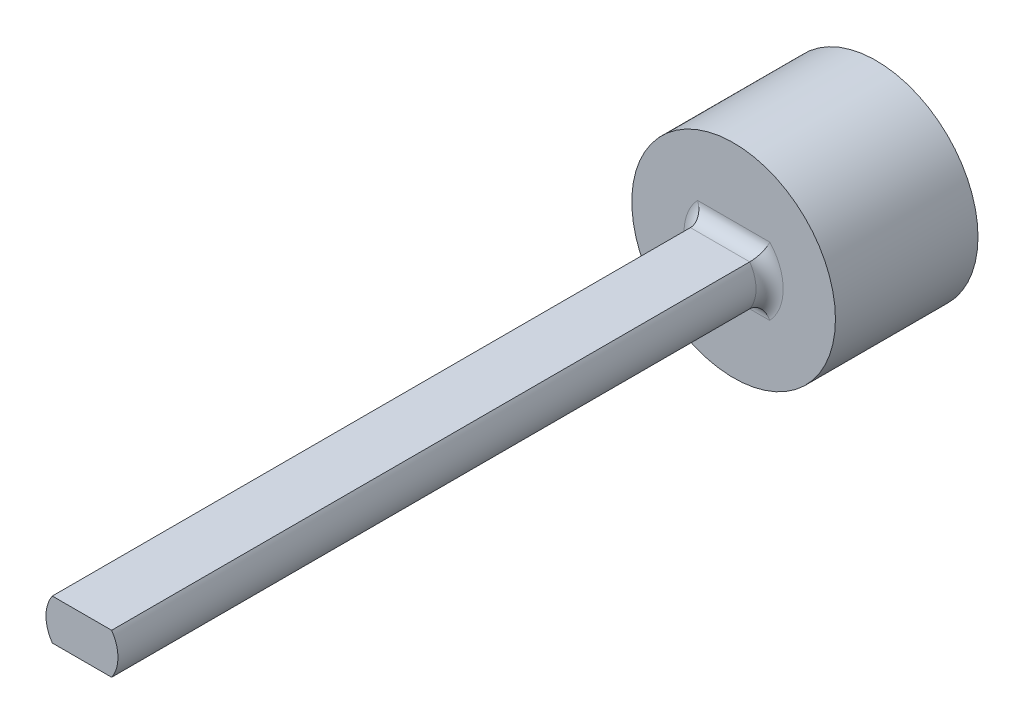
from build123d import *

# Parameters (mm, degrees)
SKETCH2_R                = 7.5
BOSS_EXTRUDE1_DEPTH      = 4
BOSS_EXTRUDE1_DEPTH_BACK = 5.5
SKETCH4_R                = 7.5
BOSS_EXTRUDE2_DEPTH      = 1
BOSS_EXTRUDE3_DEPTH      = 48
FILLET1_R                = 1


with BuildPart() as part:
    # Sketch2 → Boss-Extrude1 (new body, two sides)
    with BuildSketch(Plane.XY) as boss_extrude1_sk:
        with Locations((-178.577921964, 19.246491703)):
            Circle(SKETCH2_R)
        with BuildLine():
            ThreePointArc((-180.964561166, 16.918133172), (-181.154624072, 16.787356328), (-181.28128896, 16.594528692))
            ThreePointArc((-181.28128896, 16.594528692), (-181.41997807, 16.120570829), (-181.458725437, 15.628260596))
            ThreePointArc((-181.458725437, 15.628260596), (-181.203949235, 15.439313513), (-180.936821377, 15.26827369))
            ThreePointArc((-180.936821377, 15.26827369), (-180.490384316, 15.479377161), (-180.096604948, 15.777384768))
            ThreePointArc((-180.096604948, 15.777384768), (-179.961348857, 15.964286563), (-179.906617406, 16.188409207))
            ThreePointArc((-179.906617406, 16.188409207), (-179.860820758, 16.267909453), (-179.769487026, 16.276614146))
            ThreePointArc((-179.769487026, 16.276614146), (-179.651168987, 16.231837357), (-179.531173567, 16.191772177))
            ThreePointArc((-179.531173567, 16.191772177), (-179.465888148, 16.127309504), (-179.480632878, 16.036754465))
            ThreePointArc((-179.480632878, 16.036754465), (-179.57984376, 15.828466942), (-179.593124953, 15.598140867))
            ThreePointArc((-179.593124953, 15.598140867), (-179.476254314, 15.118336763), (-179.263655401, 14.67260991))
            ThreePointArc((-179.263655401, 14.67260991), (-178.948539196, 14.636365038), (-178.631679774, 14.621804135))
            ThreePointArc((-178.631679774, 14.621804135), (-178.350605674, 15.027843634), (-178.158586541, 15.482815477))
            ThreePointArc((-178.158586541, 15.482815477), (-178.134902228, 15.712305225), (-178.199564723, 15.933766853))
            ThreePointArc((-178.199564723, 15.933766853), (-178.199653785, 16.02551441), (-178.1249088, 16.078719761))
            ThreePointArc((-178.1249088, 16.078719761), (-178.000053977, 16.099100944), (-177.876102305, 16.124401191))
            ThreePointArc((-177.876102305, 16.124401191), (-177.787332137, 16.101217588), (-177.754823928, 16.015422258))
            ThreePointArc((-177.754823928, 16.015422258), (-177.736599312, 15.785434531), (-177.632938125, 15.579325702))
            ThreePointArc((-177.632938125, 15.579325702), (-177.29182313, 15.222238479), (-176.884843645, 14.942527158))
            ThreePointArc((-176.884843645, 14.942527158), (-176.59382257, 15.06869628), (-176.312133809, 15.21451588))
            ThreePointArc((-176.312133809, 15.21451588), (-176.271736248, 15.706693451), (-176.332928722, 16.196720191))
            ThreePointArc((-176.332928722, 16.196720191), (-176.427162379, 16.407306299), (-176.593892556, 16.566766447))
            ThreePointArc((-176.593892556, 16.566766447), (-176.639843465, 16.646177632), (-176.601715085, 16.72962731))
            ThreePointArc((-176.601715085, 16.72962731), (-176.503778228, 16.809705343), (-176.409083055, 16.893591835))
            ThreePointArc((-176.409083055, 16.893591835), (-176.320614032, 16.917899331), (-176.249563433, 16.8598525))
            ThreePointArc((-176.249563433, 16.8598525), (-176.118786588, 16.669789594), (-175.925958953, 16.543124706))
            ThreePointArc((-175.925958953, 16.543124706), (-175.45200109, 16.404435596), (-174.959690856, 16.365688229))
            ThreePointArc((-174.959690856, 16.365688229), (-174.770743774, 16.620464432), (-174.599703951, 16.88759229))
            ThreePointArc((-174.599703951, 16.88759229), (-174.810807422, 17.33402935), (-175.108815029, 17.727808718))
            ThreePointArc((-175.108815029, 17.727808718), (-175.295716824, 17.86306481), (-175.519839467, 17.91779626))
            ThreePointArc((-175.519839467, 17.91779626), (-175.599339714, 17.963592909), (-175.608044407, 18.05492664))
            ThreePointArc((-175.608044407, 18.05492664), (-175.563267617, 18.17324468), (-175.523202438, 18.2932401))
            ThreePointArc((-175.523202438, 18.2932401), (-175.458739765, 18.358525519), (-175.368184725, 18.343780789))
            ThreePointArc((-175.368184725, 18.343780789), (-175.159897203, 18.244569907), (-174.929571128, 18.231288713))
            ThreePointArc((-174.929571128, 18.231288713), (-174.449767024, 18.348159352), (-174.004040171, 18.560758265))
            ThreePointArc((-174.004040171, 18.560758265), (-173.967795299, 18.87587447), (-173.953234396, 19.192733892))
            ThreePointArc((-173.953234396, 19.192733892), (-174.359273895, 19.473807993), (-174.814245738, 19.665827125))
            ThreePointArc((-174.814245738, 19.665827125), (-175.043735485, 19.689511439), (-175.265197114, 19.624848944))
            ThreePointArc((-175.265197114, 19.624848944), (-175.356944671, 19.624759881), (-175.410150022, 19.699504867))
            ThreePointArc((-175.410150022, 19.699504867), (-175.430531205, 19.824359689), (-175.455831451, 19.948311361))
            ThreePointArc((-175.455831451, 19.948311361), (-175.432647848, 20.037081529), (-175.346852519, 20.069589738))
            ThreePointArc((-175.346852519, 20.069589738), (-175.116864792, 20.087814355), (-174.910755963, 20.191475542))
            ThreePointArc((-174.910755963, 20.191475542), (-174.553668739, 20.532590536), (-174.273957418, 20.939570022))
            ThreePointArc((-174.273957418, 20.939570022), (-174.400126541, 21.230591097), (-174.54594614, 21.512279857))
            ThreePointArc((-174.54594614, 21.512279857), (-175.038123712, 21.552677419), (-175.528150452, 21.491484944))
            ThreePointArc((-175.528150452, 21.491484944), (-175.73873656, 21.397251288), (-175.898196708, 21.23052111))
            ThreePointArc((-175.898196708, 21.23052111), (-175.977607892, 21.184570201), (-176.061057571, 21.222698582))
            ThreePointArc((-176.061057571, 21.222698582), (-176.141135604, 21.320635439), (-176.225022096, 21.415330612))
            ThreePointArc((-176.225022096, 21.415330612), (-176.249329591, 21.503799634), (-176.191282761, 21.574850234))
            ThreePointArc((-176.191282761, 21.574850234), (-176.001219855, 21.705627078), (-175.874554967, 21.898454714))
            ThreePointArc((-175.874554967, 21.898454714), (-175.735865857, 22.372412576), (-175.69711849, 22.86472281))
            ThreePointArc((-175.69711849, 22.86472281), (-175.951894692, 23.053669893), (-176.21902255, 23.224709716))
            ThreePointArc((-176.21902255, 23.224709716), (-176.665459611, 23.013606245), (-177.059238979, 22.715598637))
            ThreePointArc((-177.059238979, 22.715598637), (-177.19449507, 22.528696843), (-177.249226521, 22.304574199))
            ThreePointArc((-177.249226521, 22.304574199), (-177.295023169, 22.225073952), (-177.386356901, 22.21636926))
            ThreePointArc((-177.386356901, 22.21636926), (-177.50467494, 22.261146049), (-177.62467036, 22.301211229))
            ThreePointArc((-177.62467036, 22.301211229), (-177.68995578, 22.365673902), (-177.67521105, 22.456228941))
            ThreePointArc((-177.67521105, 22.456228941), (-177.576000167, 22.664516463), (-177.562718974, 22.894842539))
            ThreePointArc((-177.562718974, 22.894842539), (-177.679589613, 23.374646643), (-177.892188526, 23.820373495))
            ThreePointArc((-177.892188526, 23.820373495), (-178.207304731, 23.856618368), (-178.524164153, 23.871179271))
            ThreePointArc((-178.524164153, 23.871179271), (-178.805238253, 23.465139771), (-178.997257386, 23.010167929))
            ThreePointArc((-178.997257386, 23.010167929), (-179.0209417, 22.780678181), (-178.956279204, 22.559216553))
            ThreePointArc((-178.956279204, 22.559216553), (-178.956190142, 22.467468995), (-179.030935127, 22.414263644))
            ThreePointArc((-179.030935127, 22.414263644), (-179.15578995, 22.393882462), (-179.279741622, 22.368582215))
            ThreePointArc((-179.279741622, 22.368582215), (-179.36851179, 22.391765818), (-179.401019999, 22.477561148))
            ThreePointArc((-179.401019999, 22.477561148), (-179.419244616, 22.707548874), (-179.522905803, 22.913657703))
            ThreePointArc((-179.522905803, 22.913657703), (-179.864020797, 23.270744927), (-180.271000283, 23.550456248))
            ThreePointArc((-180.271000283, 23.550456248), (-180.562021357, 23.424287126), (-180.843710118, 23.278467526))
            ThreePointArc((-180.843710118, 23.278467526), (-180.88410768, 22.786289955), (-180.822915205, 22.296263215))
            ThreePointArc((-180.822915205, 22.296263215), (-180.728681548, 22.085677107), (-180.561951371, 21.926216958))
            ThreePointArc((-180.561951371, 21.926216958), (-180.516000462, 21.846805774), (-180.554128842, 21.763356096))
            ThreePointArc((-180.554128842, 21.763356096), (-180.6520657, 21.683278063), (-180.746760873, 21.59939157))
            ThreePointArc((-180.746760873, 21.59939157), (-180.835229895, 21.575084075), (-180.906280494, 21.633130906))
            ThreePointArc((-180.906280494, 21.633130906), (-181.037057339, 21.823193811), (-181.229884975, 21.9498587))
            ThreePointArc((-181.229884975, 21.9498587), (-181.703842837, 22.08854781), (-182.196153071, 22.127295177))
            ThreePointArc((-182.196153071, 22.127295177), (-182.385100154, 21.872518974), (-182.556139976, 21.605391116))
            ThreePointArc((-182.556139976, 21.605391116), (-182.345036505, 21.158954055), (-182.047028898, 20.765174687))
            ThreePointArc((-182.047028898, 20.765174687), (-181.860127103, 20.629918596), (-181.63600446, 20.575187146))
            ThreePointArc((-181.63600446, 20.575187146), (-181.556504213, 20.529390497), (-181.54779952, 20.438056766))
            ThreePointArc((-181.54779952, 20.438056766), (-181.59257631, 20.319738726), (-181.632641489, 20.199743306))
            ThreePointArc((-181.632641489, 20.199743306), (-181.697104162, 20.134457887), (-181.787659202, 20.149202617))
            ThreePointArc((-181.787659202, 20.149202617), (-181.995946724, 20.248413499), (-182.226272799, 20.261694692))
            ThreePointArc((-182.226272799, 20.261694692), (-182.706076904, 20.144824054), (-183.151803756, 19.932225141))
            ThreePointArc((-183.151803756, 19.932225141), (-183.188048629, 19.617108936), (-183.202609531, 19.300249514))
            ThreePointArc((-183.202609531, 19.300249514), (-182.796570032, 19.019175413), (-182.34159819, 18.82715628))
            ThreePointArc((-182.34159819, 18.82715628), (-182.112108442, 18.803471967), (-181.890646814, 18.868134462))
            ThreePointArc((-181.890646814, 18.868134462), (-181.798899256, 18.868223525), (-181.745693905, 18.793478539))
            ThreePointArc((-181.745693905, 18.793478539), (-181.725312723, 18.668623716), (-181.700012476, 18.544672045))
            ThreePointArc((-181.700012476, 18.544672045), (-181.723196079, 18.455901876), (-181.808991408, 18.423393667))
            ThreePointArc((-181.808991408, 18.423393667), (-182.038979135, 18.405169051), (-182.245087964, 18.301507864))
            ThreePointArc((-182.245087964, 18.301507864), (-182.602175188, 17.96039287), (-182.881886509, 17.553413384))
            ThreePointArc((-182.881886509, 17.553413384), (-182.755717387, 17.262392309), (-182.609897787, 16.980703549))
            ThreePointArc((-182.609897787, 16.980703549), (-182.117720216, 16.940305987), (-181.627693476, 17.001498461))
            ThreePointArc((-181.627693476, 17.001498461), (-181.417107367, 17.095732118), (-181.257647219, 17.262462296))
            ThreePointArc((-181.257647219, 17.262462296), (-181.178236035, 17.308413205), (-181.094786356, 17.270284824))
            ThreePointArc((-181.094786356, 17.270284824), (-181.014708323, 17.172347967), (-180.930821831, 17.077652794))
            ThreePointArc((-180.930821831, 17.077652794), (-180.906514336, 16.989183772), (-180.964561166, 16.918133172))
        make_face(mode=Mode.SUBTRACT)
    extrude(amount=BOSS_EXTRUDE1_DEPTH)
    extrude(boss_extrude1_sk.sketch, amount=-BOSS_EXTRUDE1_DEPTH_BACK)

    # Sketch4 → Boss-Extrude2 (add)
    with BuildSketch(Plane.XY.offset(4)):
        with Locations((-178.577921964, 19.246491703)):
            Circle(SKETCH4_R)
    extrude(amount=BOSS_EXTRUDE2_DEPTH)

    # Sketch6 → Boss-Extrude3 (add)
    with BuildSketch(Plane.XY.offset(5)):
        with BuildLine():
            Line((-180.762527191, 20.746491703), (-176.393316736, 20.746491703))
            ThreePointArc((-176.393316736, 20.746491703), (-175.927921964, 19.246491703), (-176.393316736, 17.746491703))
            Line((-176.393316736, 17.746491703), (-180.762527191, 17.746491703))
            ThreePointArc((-180.762527191, 17.746491703), (-181.227921964, 19.246491703), (-180.762527191, 20.746491703))
        make_face()
    extrude(amount=BOSS_EXTRUDE3_DEPTH)

    # Fillet1
    fillet1_edges = [part.edges().sort_by_distance(p)[0] for p in [
        (-175.927921964, 19.246491703, 5),
        (-178.577921964, 20.746491703, 5),
        (-181.227921964, 19.246491703, 5),
        (-178.577921964, 17.746491703, 5),
    ]]
    fillet(fillet1_edges, radius=FILLET1_R)


solid = part.part
